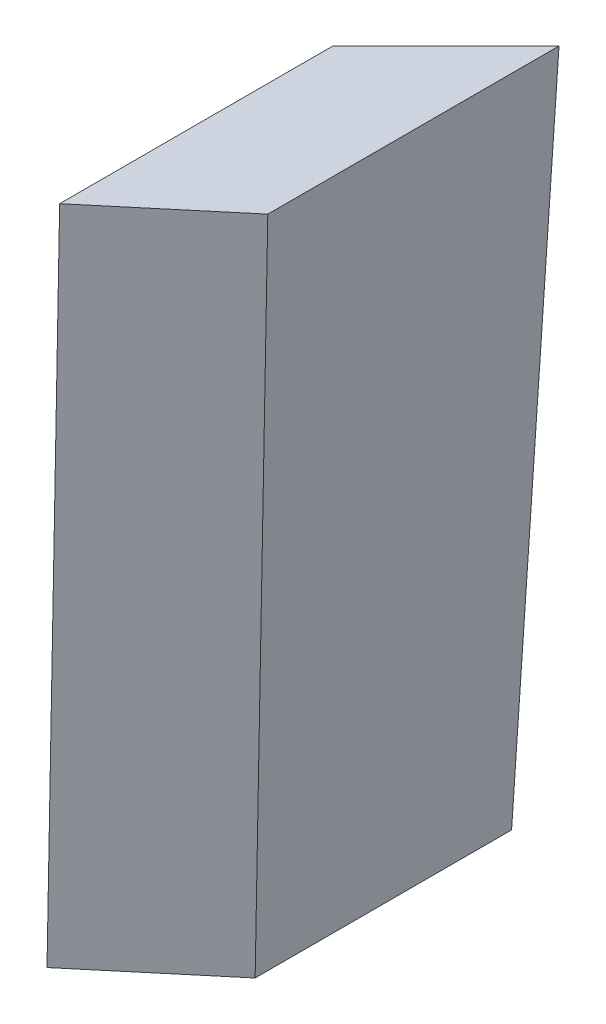
from build123d import *


with BuildPart() as part:
    # Croquis1 → Recubrir1 section 0
    with BuildSketch(Plane(origin=(0, 0, 0), x_dir=(1, 0, 0), z_dir=(0, 1, 0))):
        Polygon((0, 0), (0, 26.32), (12.495805492, 38.827487562), (12.495805492, 10.497487562), align=None)
    # Croquis2 → Recubrir1 section 1
    with BuildSketch(Plane(origin=(0, 75, 0), x_dir=(1, 0, 0), z_dir=(0, 1, 0))):
        Polygon((2.62, -1.22), (15.115805492, 9.277487562), (15.115805492, 41.447487562), (2.62, 28.94), align=None)
    loft()


solid = part.part
